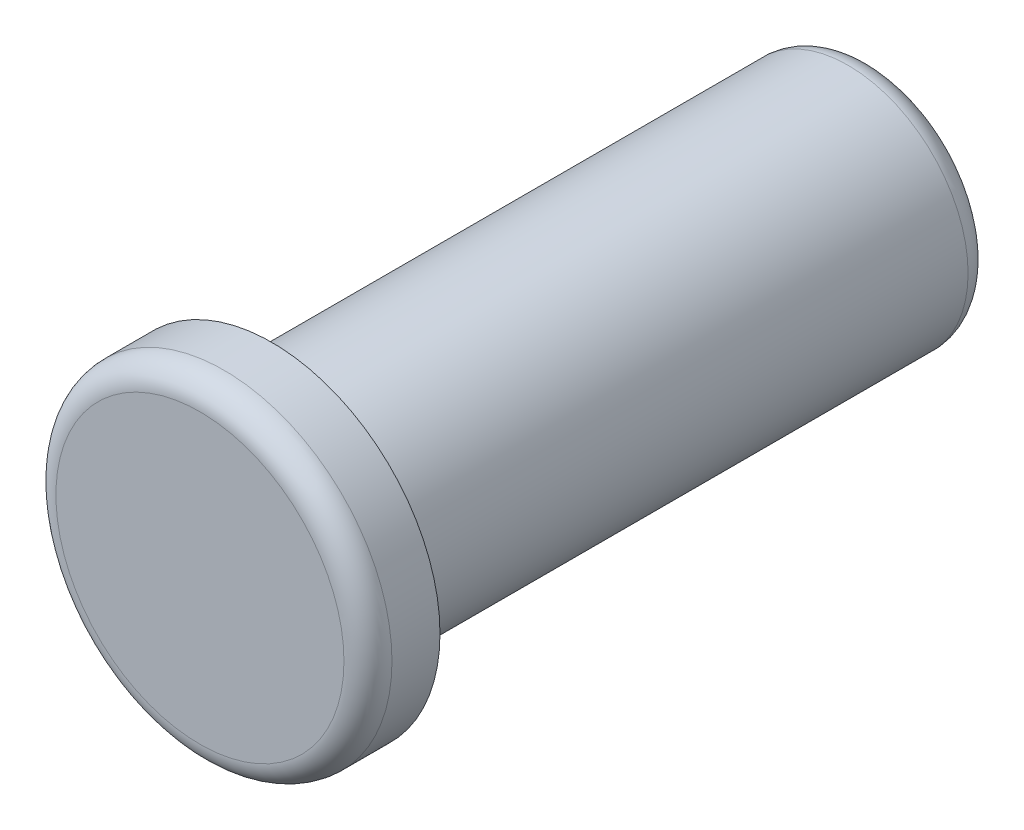
from build123d import *

# Parameters (mm, degrees)
SKICA1_R                = 7
P_IDAT_VYSUNUT_M1_DEPTH = 3
SKICA2_R                = 5
P_IDAT_VYSUNUT_M2_DEPTH = 25
ZAOBLIT1_R              = 1


with BuildPart() as part:
    # Skica1 → Přidat vysunutím1 (new body)
    with BuildSketch(Plane.XY):
        Circle(SKICA1_R)
    extrude(amount=P_IDAT_VYSUNUT_M1_DEPTH)

    # Skica2 → Přidat vysunutím2 (add)
    with BuildSketch(Plane(origin=(0, 0, 0), x_dir=(-1, 0, 0), z_dir=(0, 0, -1))):
        Circle(SKICA2_R)
    extrude(amount=P_IDAT_VYSUNUT_M2_DEPTH)

    # Zaoblit1
    zaoblit1_edges = [part.edges().sort_by_distance(p)[0] for p in [
        (-7, 0, 3),
        (5, 0, -25),
    ]]
    fillet(zaoblit1_edges, radius=ZAOBLIT1_R)


solid = part.part
